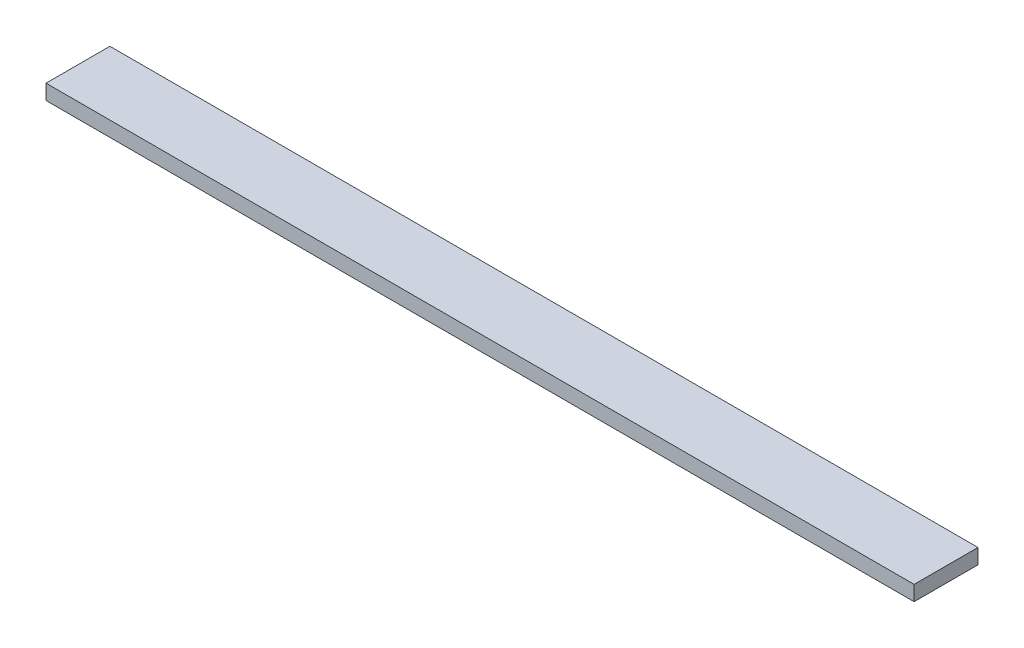
from build123d import *

# Parameters (mm, degrees)
SKETCH_1_W      = 11550
SKETCH_1_H      = 850
EXTRUDE_1_DEPTH = 200


with BuildPart() as part:
    # 草圖1 → 填料-伸長1 (new body)
    with BuildSketch(Plane(origin=(0, 0, 0), x_dir=(1, 0, 0), z_dir=(0, 1, 0))):
        Rectangle(SKETCH_1_W, SKETCH_1_H)
    extrude(amount=EXTRUDE_1_DEPTH)


solid = part.part
